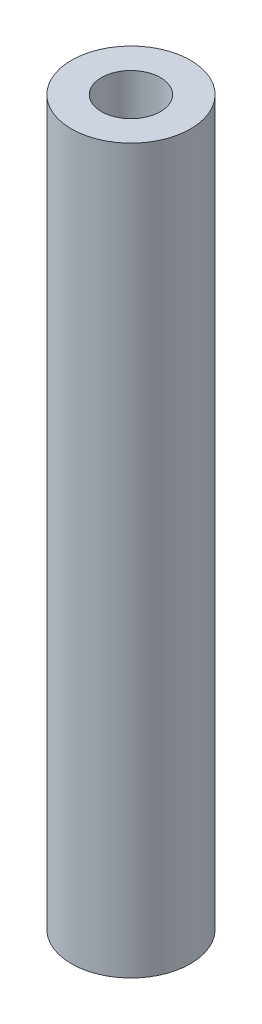
from build123d import *

# Parameters (mm, degrees)
SKETCH1_R           = 25.508311209
SKETCH1_R_2         = 12.651769435
BOSS_EXTRUDE1_DEPTH = 309.88


with BuildPart() as part:
    # Sketch1 → Boss-Extrude1 (new body)
    with BuildSketch(Plane(origin=(0, 0, 0), x_dir=(1, 0, 0), z_dir=(0, 1, 0))):
        Circle(SKETCH1_R)
        Circle(SKETCH1_R_2, mode=Mode.SUBTRACT)
    extrude(amount=BOSS_EXTRUDE1_DEPTH)


solid = part.part
